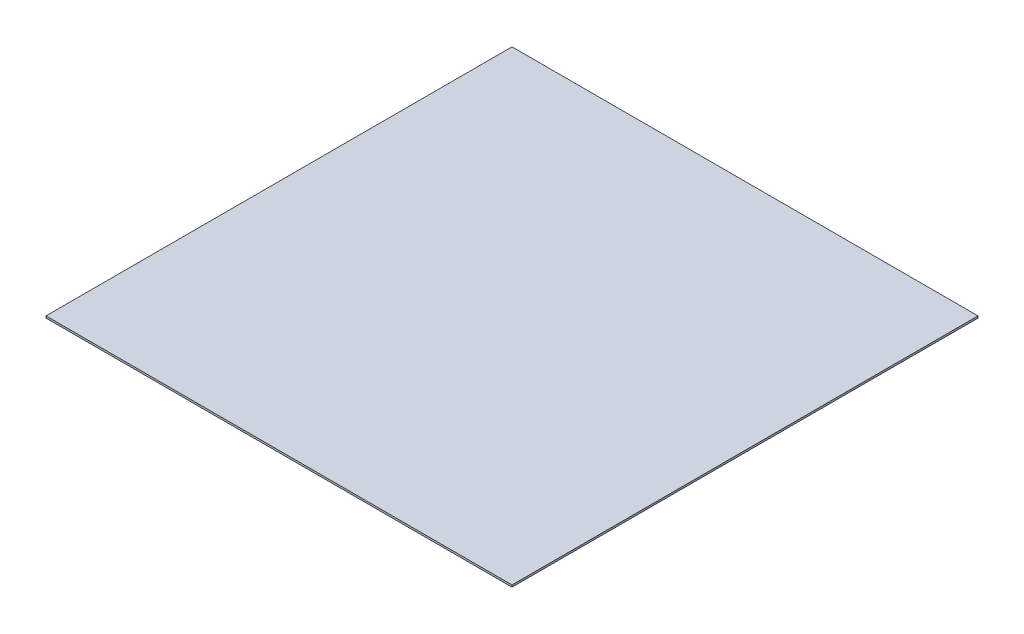
from build123d import *

# Parameters (mm, degrees)
SKETCH1_W      = 120
SKETCH1_H      = 120
EXTRUDE1_DEPTH = 0.5


with BuildPart() as part:
    # Sketch1 → Extrude1 (new body)
    with BuildSketch(Plane(origin=(0, 0, 0), x_dir=(1, 0, 0), z_dir=(0, 1, 0))):
        Rectangle(SKETCH1_W, SKETCH1_H)
    extrude(amount=EXTRUDE1_DEPTH)


solid = part.part
